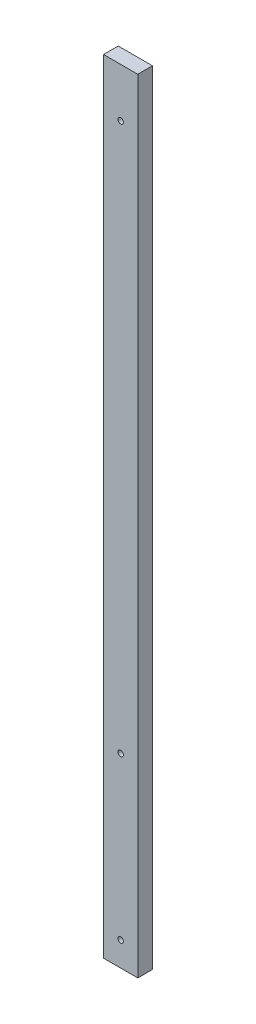
from build123d import *

# Parameters (mm, degrees)
SKETCH1_W               = 88.9
SKETCH1_H               = 38.1
BOSS_EXTRUDE1_DEPTH     = 2032
SKETCH2_R               = 7.14375
CUT_EXTRUDE1_DEPTH      = 1
CUT_EXTRUDE1_DEPTH_BACK = 39.1


with BuildPart() as part:
    # Sketch1 → Boss-Extrude1 (new body)
    with BuildSketch(Plane(origin=(0, 0, 0), x_dir=(1, 0, 0), z_dir=(0, 1, 0))):
        Rectangle(SKETCH1_W, SKETCH1_H)
    extrude(amount=BOSS_EXTRUDE1_DEPTH)

    # Sketch2 → Cut-Extrude1 (cut, two sides)
    with BuildSketch(Plane.XY.offset(19.05)) as cut_extrude1_sk:
        with Locations((0, 63.5)):
            Circle(SKETCH2_R)
        with Locations((0, 482.6)):
            Circle(SKETCH2_R)
        with Locations((0, 1905)):
            Circle(SKETCH2_R)
    extrude(amount=CUT_EXTRUDE1_DEPTH, mode=Mode.SUBTRACT)
    extrude(cut_extrude1_sk.sketch, amount=-CUT_EXTRUDE1_DEPTH_BACK, mode=Mode.SUBTRACT)


solid = part.part
